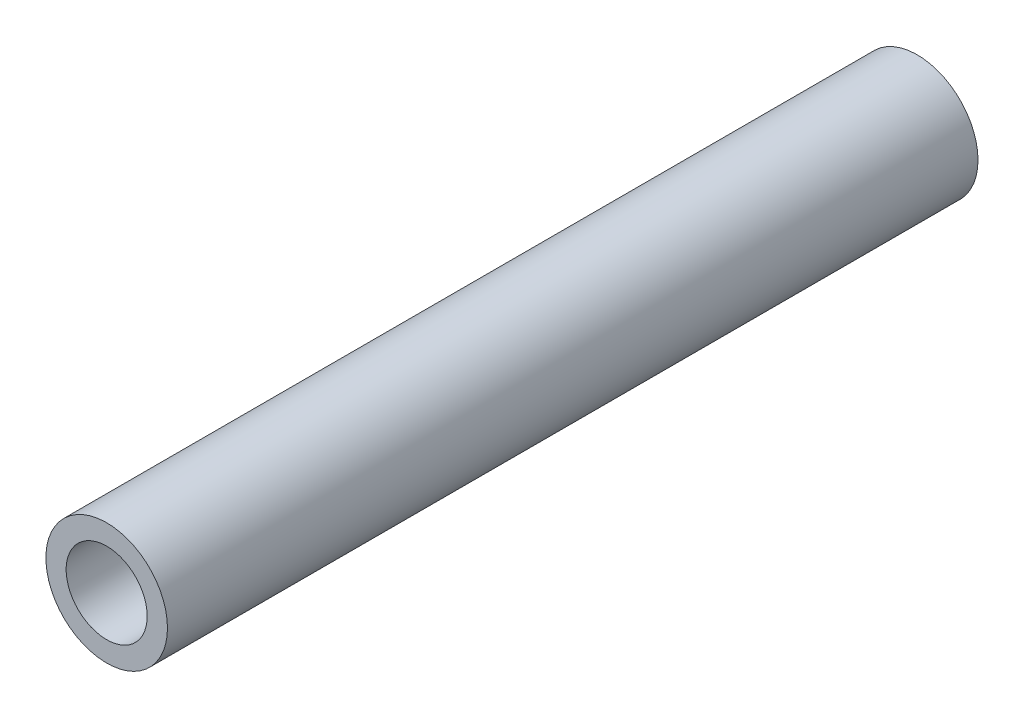
from build123d import *

# Parameters (mm, degrees)
SKETCH1_R           = 1.5
SKETCH1_R_2         = 1
BOSS_EXTRUDE1_DEPTH = 20


with BuildPart() as part:
    # Sketch1 → Boss-Extrude1 (new body)
    with BuildSketch(Plane.XY):
        Circle(SKETCH1_R)
        Circle(SKETCH1_R_2, mode=Mode.SUBTRACT)
    extrude(amount=BOSS_EXTRUDE1_DEPTH)


solid = part.part
